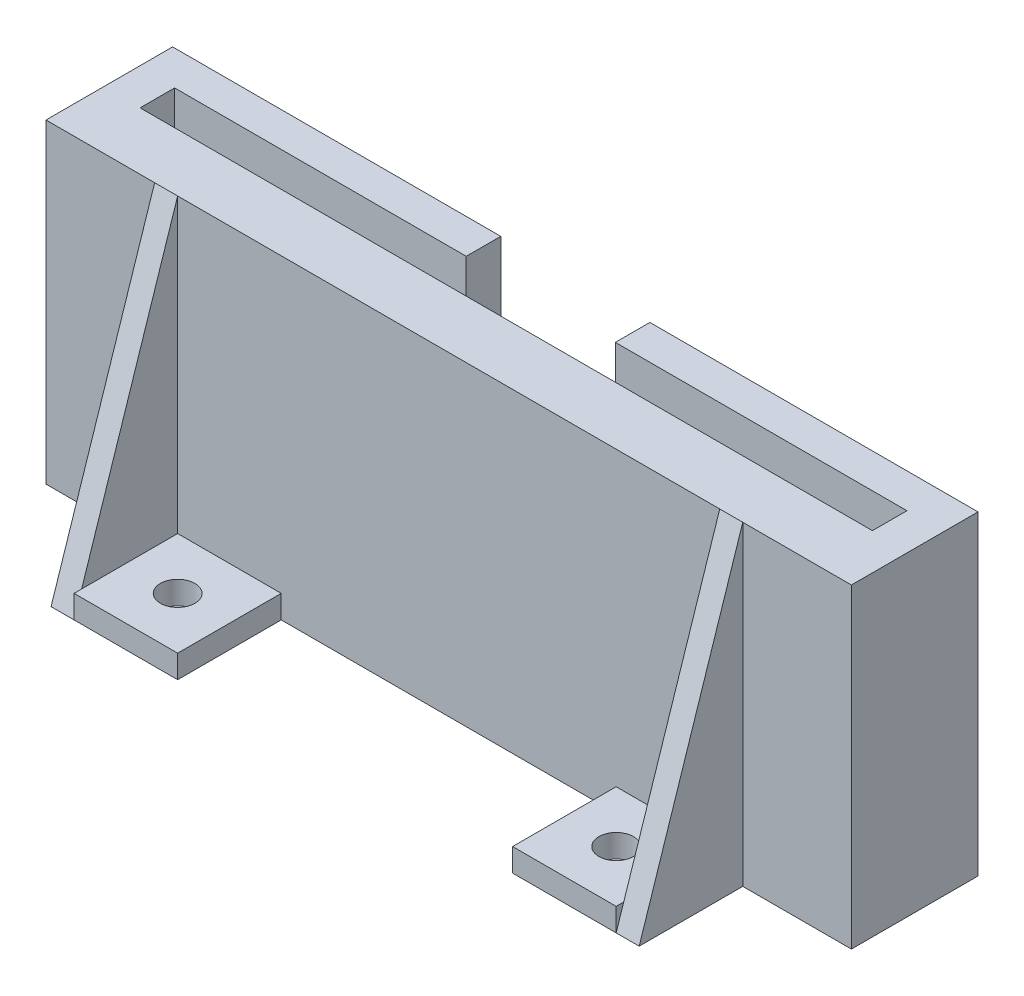
from build123d import *

# Parameters (mm, degrees)
SKETCH1_W           = 69.977
SKETCH1_H           = 11
BOSS_EXTRUDE1_DEPTH = 2
BOSS_EXTRUDE2_START = 2
SKETCH1_4_W         = 3.175
SKETCH1_4_H         = 3
BOSS_EXTRUDE2_DEPTH = 25.4
SKETCH3_W           = 9
SKETCH3_H           = 9
SKETCH3_R           = 1.5
BOSS_EXTRUDE3_DEPTH = 2
BOSS_EXTRUDE4_DEPTH = 2
BOSS_EXTRUDE5_START = -47.1
BOSS_EXTRUDE5_DEPTH = 2


with BuildPart() as part:
    # Sketch1 → Boss-Extrude1 (new body)
    with BuildSketch(Plane(origin=(0, 0, 0), x_dir=(1, 0, 0), z_dir=(0, 1, 0))):
        Rectangle(SKETCH1_W, SKETCH1_H)
    extrude(amount=BOSS_EXTRUDE1_DEPTH)

    # Sketch1_4 → Boss-Extrude2 (add)
    with BuildSketch(Plane(origin=(0, 0, 0), x_dir=(1, 0, 0), z_dir=(0, 1, 0)).offset(BOSS_EXTRUDE2_START)):
        Polygon((34.9885, -5.5), (34.9885, -0.5), (31.8135, -0.5), (-31.8135, -0.5), (-34.9885, -0.5), (-34.9885, -5.5), align=None)
        Polygon((-6.477, 2.5), (-6.477, 5.5), (-34.9885, 5.5), (-34.9885, 2.5), (-31.8135, 2.5), align=None)
        Polygon((34.9885, 2.5), (34.9885, 5.5), (6.477, 5.5), (6.477, 2.5), (31.8135, 2.5), align=None)
        with Locations((-33.401, 1)):
            Rectangle(SKETCH1_4_W, SKETCH1_4_H)
        with Locations((33.401, 1)):
            Rectangle(SKETCH1_4_W, SKETCH1_4_H)
    extrude(amount=BOSS_EXTRUDE2_DEPTH)

    # Sketch3 → Boss-Extrude3 (add)
    with BuildSketch(Plane.XZ):
        with Locations((-19.05, 10)):
            Rectangle(SKETCH3_W, SKETCH3_H)
        with Locations((-19.05, 10)):
            Circle(SKETCH3_R, mode=Mode.SUBTRACT)
        with Locations((19.05, 10)):
            Rectangle(SKETCH3_W, SKETCH3_H)
        with Locations((19.05, 10)):
            Circle(SKETCH3_R, mode=Mode.SUBTRACT)
    extrude(amount=-BOSS_EXTRUDE3_DEPTH)

    # Sketch4 → Boss-Extrude4 (add)
    with BuildSketch(Plane.ZY.offset(23.55)):
        Polygon((14.5, 0), (5.5, 27.4), (5.5, 0), align=None)
    extrude(amount=BOSS_EXTRUDE4_DEPTH)

    # Sketch4_2 → Boss-Extrude5 (add)
    with BuildSketch(Plane.ZY.offset(23.55).offset(BOSS_EXTRUDE5_START)):
        Polygon((14.5, 0), (5.5, 27.4), (5.5, 0), align=None)
    extrude(amount=-BOSS_EXTRUDE5_DEPTH)


solid = part.part
